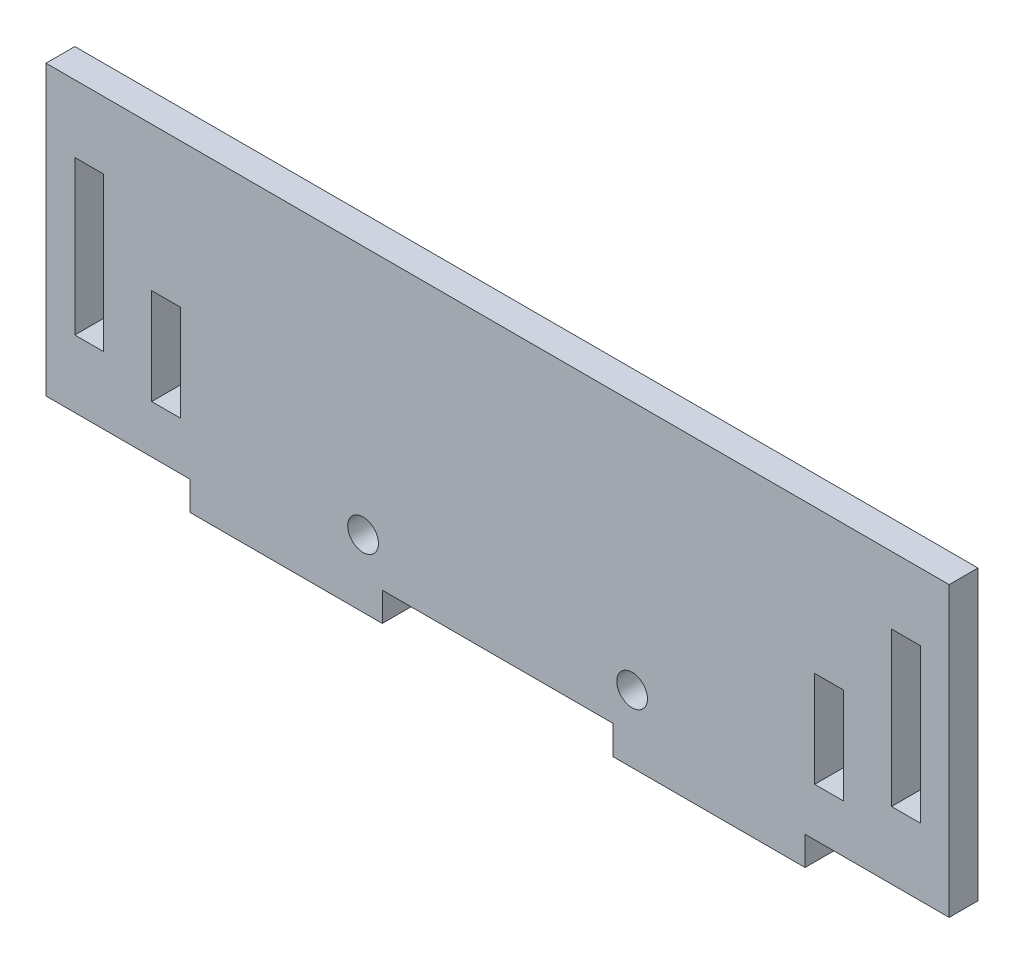
from build123d import *

# Parameters (mm, degrees)
SKETCH_1_R      = 1.6
SKETCH_1_W      = 3
SKETCH_1_H      = 10
EXTRUDE_1_DEPTH = 3


with BuildPart() as part:
    # 草图1 → 凸台-拉伸1 (new body)
    with BuildSketch(Plane.XY):
        Polygon((32, 0), (44, 0), (56, 0), (56, -3), (76, -3), (76, 0), (88, 0), (91, 0), (91, 30), (88, 30), (0, 30), (-3, 30), (-3, 0), (0, 0), (12, 0), (12, -3), (32, -3), align=None)
        with Locations((30, 4)):
            Circle(SKETCH_1_R, mode=Mode.SUBTRACT)
        with Locations((9.5, 10)):
            Rectangle(SKETCH_1_W, SKETCH_1_H, mode=Mode.SUBTRACT)
        with BuildLine():
            ThreePointArc((59.6, 4), (58, 2.4), (56.4, 4))
            ThreePointArc((56.4, 4), (58, 5.6), (59.6, 4))
        make_face(mode=Mode.SUBTRACT)
        with Locations((78.5, 10)):
            Rectangle(SKETCH_1_W, SKETCH_1_H, mode=Mode.SUBTRACT)
        Polygon((0, 15), (0, 23), (3, 23), (3, 15), (3, 7), (0, 7), align=None, mode=Mode.SUBTRACT)
        Polygon((85, 23), (88, 23), (88, 15), (88, 7), (85, 7), (85, 15), align=None, mode=Mode.SUBTRACT)
    extrude(amount=EXTRUDE_1_DEPTH)


solid = part.part
